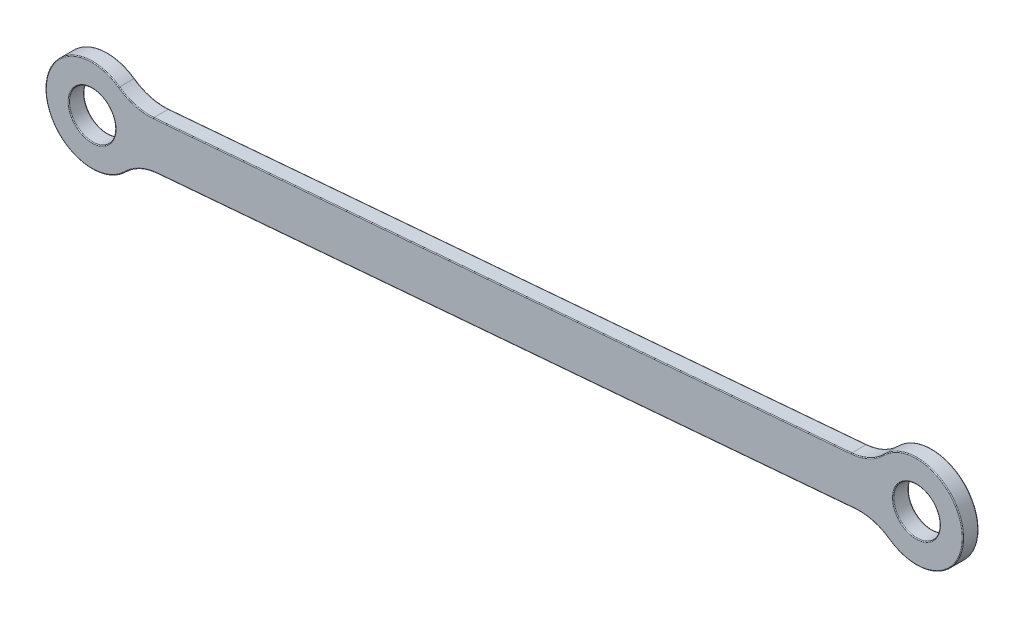
from build123d import *

# Parameters (mm, degrees)
SZKIC2_R                    = 4.5
DODANIE_WYCI_GNI_CIE1_DEPTH = 3
ZAOKR_GLENIE1_R             = 10
ZAOKR_GLENIE2_R             = 10
ZAOKR_GLENIE3_R             = 10
ZAOKR_GLENIE4_R             = 10
ZAOKR_GLENIE5_R             = 0.15


with BuildPart() as part:
    # Szkic2 → Dodanie-wyciągnięcie1 (new body)
    with BuildSketch(Plane.XY):
        with BuildLine():
            ThreePointArc((-238.974611052, 218.044531173), (-255.334133629, 212.157075316), (-238.222643555, 209.076000363))
            Line((-238.222643555, 209.076000363), (-94.31604686, 221.141865505))
            ThreePointArc((-94.31604686, 221.141865505), (-77.956524282, 227.029321361), (-95.068014356, 230.110396314))
            Line((-95.068014356, 230.110396314), (-238.974611052, 218.044531173))
        make_face()
        with Locations((-246.36560282, 212.909042813)):
            Circle(SZKIC2_R, mode=Mode.SUBTRACT)
        with Locations((-86.925055092, 226.277353864)):
            Circle(SZKIC2_R, mode=Mode.SUBTRACT)
    extrude(amount=DODANIE_WYCI_GNI_CIE1_DEPTH)

    # Zaokrąglenie1
    zaokr_glenie1_edges = [part.edges().sort_by_distance(p)[0] for p in [
        (-238.974611052, 218.044531173, 1.5),
    ]]
    fillet(zaokr_glenie1_edges, radius=ZAOKR_GLENIE1_R)

    # Zaokrąglenie2
    zaokr_glenie2_edges = [part.edges().sort_by_distance(p)[0] for p in [
        (-238.222643555, 209.076000363, 1.5),
    ]]
    fillet(zaokr_glenie2_edges, radius=ZAOKR_GLENIE2_R)

    # Zaokrąglenie3
    zaokr_glenie3_edges = [part.edges().sort_by_distance(p)[0] for p in [
        (-95.068014356, 230.110396314, 1.5),
    ]]
    fillet(zaokr_glenie3_edges, radius=ZAOKR_GLENIE3_R)

    # Zaokrąglenie4
    zaokr_glenie4_edges = [part.edges().sort_by_distance(p)[0] for p in [
        (-94.31604686, 221.141865505, 1.5),
    ]]
    fillet(zaokr_glenie4_edges, radius=ZAOKR_GLENIE4_R)

    # Zaokrąglenie5
    zaokr_glenie5_edges = [part.edges().sort_by_distance(p)[0] for p in [
        (-91.425055092, 226.277353864, 0),
        (-255.334133629, 212.157075316, 0),
        (-255.334133629, 212.157075316, 3),
        (-167.021312704, 224.077463743, 0),
        (-167.021312704, 224.077463743, 3),
        (-237.986721831, 218.740260342, 0),
        (-237.986721831, 218.740260342, 3),
        (-250.86560282, 212.909042813, 3),
        (-166.269345207, 215.108932934, 0),
        (-166.269345207, 215.108932934, 3),
        (-237.132694559, 208.554487777, 0),
        (-237.132694559, 208.554487777, 3),
        (-96.157963353, 230.6319089, 0),
        (-96.157963353, 230.6319089, 3),
        (-77.956524282, 227.029321361, 0),
        (-77.956524282, 227.029321361, 3),
        (-95.303936081, 220.446136335, 0),
        (-95.303936081, 220.446136335, 3),
        (-91.425055092, 226.277353864, 3),
        (-250.86560282, 212.909042813, 0),
    ]]
    fillet(zaokr_glenie5_edges, radius=ZAOKR_GLENIE5_R)


solid = part.part
